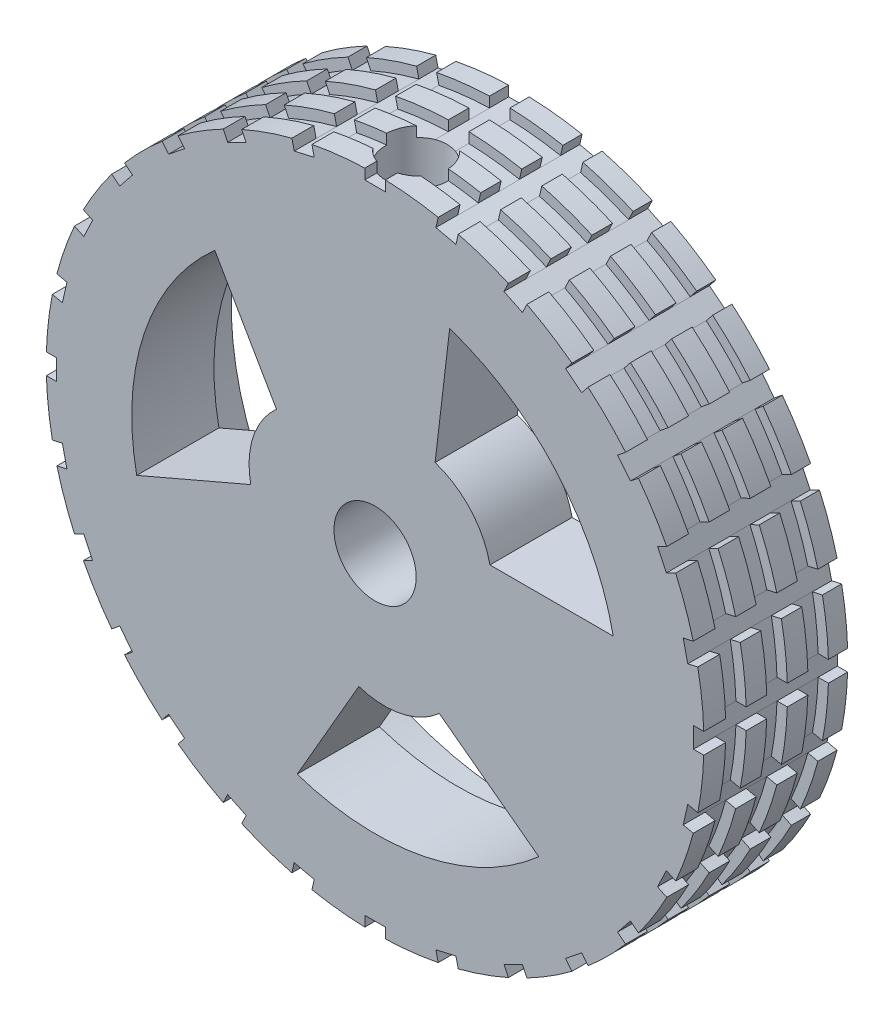
from build123d import *

# Parameters (mm, degrees)
SKETCH6_W          = 1
SKETCH6_H          = 0.5
CUT_EXTRUDE3_DEPTH = 10
CIRPATTERN3_COUNT  = 28
LPATTERN1_COUNT    = 3
LPATTERN1_PITCH    = 2
CUT_EXTRUDE6_DEPTH = 10
CIRPATTERN8_COUNT  = 3


with BuildPart() as part:
    # Sketch1 → Revolve1 (revolve)
    with BuildSketch(Plane(origin=(0, 0, 0), x_dir=(0, 0, -1), z_dir=(1, 0, 0))):
        Polygon((0, 16), (0, 2), (5, 2), (5, 4), (4, 4), (4, 14), (7, 14), (7, 16), align=None)
    revolve(axis=Axis((0, 0, 0), (0, 0, -1)))

    # Sketch3 → Cut-Revolve1 (revolve, cut)
    with BuildSketch(Plane(origin=(0, 0, 0), x_dir=(0, 0, -1), z_dir=(1, 0, 0))):
        Polygon((2, 0), (2.9, 0), (2.9, 11.5), (3.5, 11.5), (3.5, 16), (2, 16), align=None)
    revolve(axis=Axis((0, 0, -2), (0, 1, 0)), mode=Mode.SUBTRACT)

    # Sketch6 → Cut-Revolve2 (revolve, cut)
    with BuildSketch(Plane(origin=(0, 0, 0), x_dir=(0, 0, -1), z_dir=(1, 0, 0))):
        with Locations((5.565612744, 15.75)):
            Rectangle(SKETCH6_W, SKETCH6_H)
    cut_revolve2 = revolve(axis=Axis((0, 0, 0), (0, 0, -1)), mode=Mode.SUBTRACT)

    # Sketch7 → Cut-Extrude3 (cut)
    with BuildSketch(Plane(origin=(0, 0, -7), x_dir=(-1, 0, 0), z_dir=(0, 0, -1))):
        with BuildLine():
            Line((-0.5, 15.992185592), (-0.5, 15.492185592))
            Line((-0.5, 15.492185592), (0.5, 15.492185592))
            Line((0.5, 15.492185592), (0.5, 15.992185592))
            ThreePointArc((0.5, 15.992185592), (0, 16), (-0.5, 15.992185592))
        make_face()
    cut_extrude3 = extrude(amount=-CUT_EXTRUDE3_DEPTH, mode=Mode.SUBTRACT)

    # CirPattern3: Cut-Extrude3 ×28 about axis
    cirpattern3_axis = Axis((0, 0, 0), (0, 0, 1))
    for i in range(1, CIRPATTERN3_COUNT):
        add(cut_extrude3.rotate(cirpattern3_axis, i * 360 / CIRPATTERN3_COUNT), mode=Mode.SUBTRACT)

    # LPattern1: Cut-Revolve2 ×3
    with Locations(*[(0, 0, i * LPATTERN1_PITCH) for i in range(1, LPATTERN1_COUNT)]):
        add(cut_revolve2, mode=Mode.SUBTRACT)

    # Sketch9 → Cut-Extrude6 (cut)
    with BuildSketch(Plane(origin=(0, 0, -4), x_dir=(-1, 0, 0), z_dir=(0, 0, -1))):
        with BuildLine():
            Line((-11.587731975, 2.314537842), (-5.587731975, 2.314537842))
            ThreePointArc((-5.587731975, 2.314537842), (-4.653833714, 4.162515417), (-2.921065309, 5.295961812))
            Line((-2.921065309, 5.295961812), (-3.629269241, 11.295961812))
            ThreePointArc((-3.629269241, 11.295961812), (-8.811798241, 7.871494934), (-11.587731975, 2.314537842))
        make_face()
    cut_extrude6 = extrude(amount=-CUT_EXTRUDE6_DEPTH, mode=Mode.SUBTRACT)

    # CirPattern8: Cut-Extrude6 ×3 about axis
    cirpattern8_axis = Axis((0, 0, 0), (0, 0, 1))
    for i in range(1, CIRPATTERN8_COUNT):
        add(cut_extrude6.rotate(cirpattern8_axis, i * 360 / CIRPATTERN8_COUNT), mode=Mode.SUBTRACT)


solid = part.part
